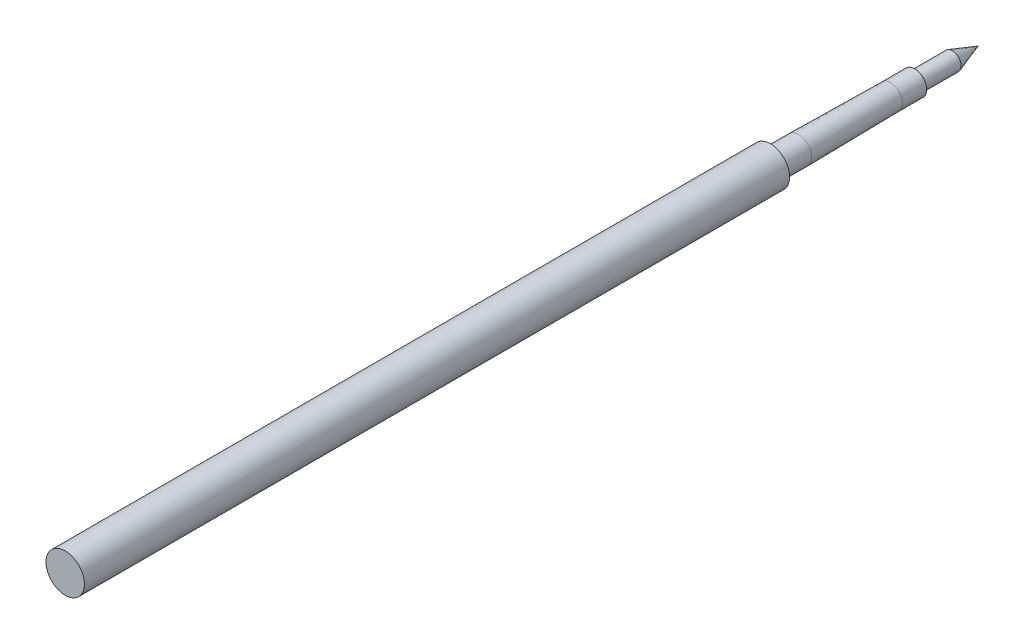
from build123d import *


with BuildPart() as part:
    # 草图1 → 旋转1 (revolve)
    with BuildSketch(Plane(origin=(0, 0, 0), x_dir=(1, 0, 0), z_dir=(0, 1, 0))):
        Polygon((0, 0), (-2.4, 0), (-2.4, 88), (-1.65, 88), (-1.65, 91.5), (-1.5, 103), (-1.5, 106), (-1.1, 106), (-1.1, 110.7), (0, 113.9), align=None)
    revolve(axis=Axis((0, 0, 0), (0, 0, -1)))


solid = part.part
